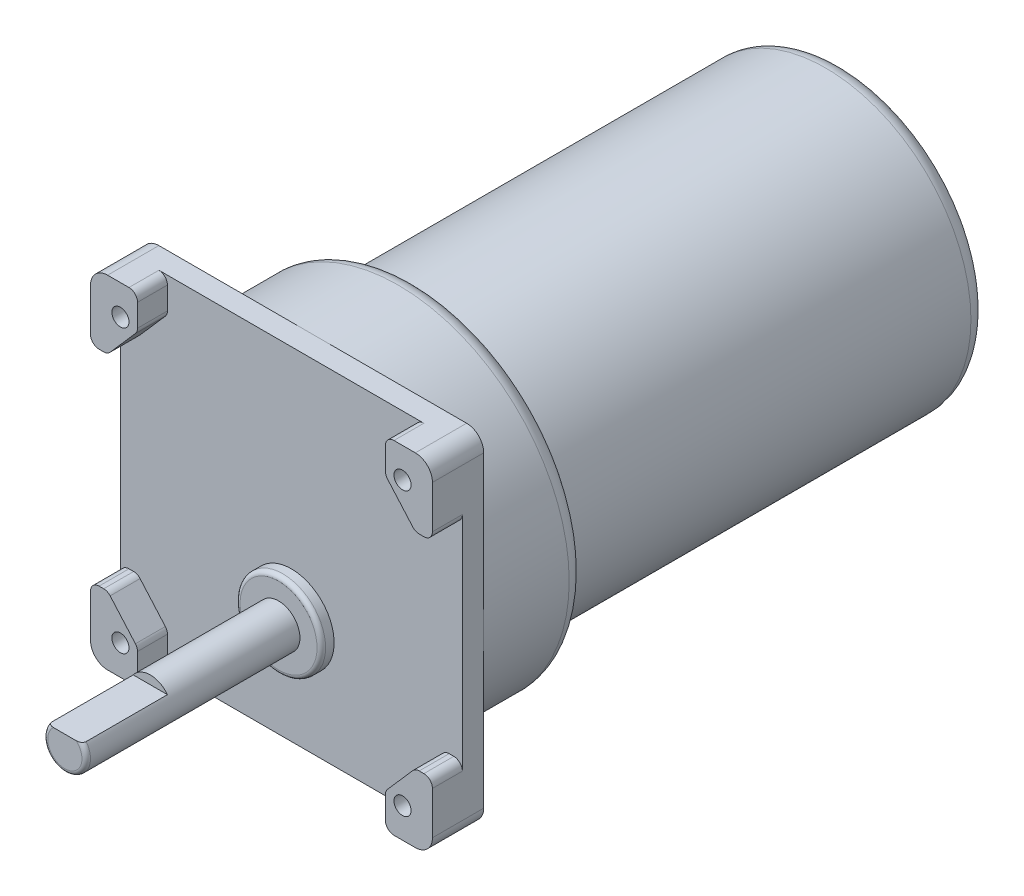
from build123d import *

# Parameters (mm, degrees)
SKETCH1_R               = 40
BOSS_EXTRUDE1_DEPTH     = 24
SKETCH2_W               = 80
SKETCH2_H               = 80
SKETCH2_R               = 2
BOSS_EXTRUDE2_DEPTH     = 5
FILLET1_R               = 4
SKETCH3_R               = 34
BOSS_EXTRUDE3_DEPTH     = 100
FILLET2_R               = 4
SKETCH4_R               = 10
BOSS_EXTRUDE4_DEPTH     = 3
SKETCH5_R               = 5
BOSS_EXTRUDE5_DEPTH     = 50
FILLET3_R               = 1
FILLET4_R               = 1
SKETCH6_W               = 26.979088542
SKETCH6_H               = 2
CUT_EXTRUDE1_DEPTH      = 1
CUT_EXTRUDE1_DEPTH_BACK = 81
SKETCH8_R               = 2
BOSS_EXTRUDE6_DEPTH     = 7
FILLET5_R               = 2


with BuildPart() as part:
    # Sketch1 → Boss-Extrude1 (new body)
    with BuildSketch(Plane.XY):
        Circle(SKETCH1_R)
    extrude(amount=BOSS_EXTRUDE1_DEPTH)

    # Sketch2 → Boss-Extrude2 (add)
    with BuildSketch(Plane.XY.offset(24)):
        Rectangle(SKETCH2_W, SKETCH2_H)
        with Locations((33, -33)):
            Circle(SKETCH2_R, mode=Mode.SUBTRACT)
        with Locations((-33, 33)):
            Circle(SKETCH2_R, mode=Mode.SUBTRACT)
        with Locations((33, 33)):
            Circle(SKETCH2_R, mode=Mode.SUBTRACT)
        with Locations((-33, -33)):
            Circle(SKETCH2_R, mode=Mode.SUBTRACT)
    extrude(amount=BOSS_EXTRUDE2_DEPTH)

    # Fillet1
    fillet1_edges = [part.edges().sort_by_distance(p)[0] for p in [
        (40, 40, 26.5),
        (-40, 40, 26.5),
        (-40, -40, 26.5),
        (40, -40, 26.5),
    ]]
    fillet(fillet1_edges, radius=FILLET1_R)

    # Sketch3 → Boss-Extrude3 (add)
    with BuildSketch(Plane(origin=(0, 0, 0), x_dir=(-1, 0, 0), z_dir=(0, 0, -1))):
        Circle(SKETCH3_R)
    extrude(amount=BOSS_EXTRUDE3_DEPTH)

    # Fillet2
    fillet2_edges = [part.edges().sort_by_distance(p)[0] for p in [
        (-40, 0, 0),
        (34, 0, -100),
    ]]
    fillet(fillet2_edges, radius=FILLET2_R)

    # Sketch4 → Boss-Extrude4 (add)
    with BuildSketch(Plane.XY.offset(29)):
        with Locations((0, -15)):
            Circle(SKETCH4_R)
    extrude(amount=BOSS_EXTRUDE4_DEPTH)

    # Sketch5 → Boss-Extrude5 (add)
    with BuildSketch(Plane.XY.offset(32)):
        with Locations((0, -15)):
            Circle(SKETCH5_R)
    extrude(amount=BOSS_EXTRUDE5_DEPTH)

    # Fillet3
    fillet3_edges = [part.edges().sort_by_distance(p)[0] for p in [
        (-10, -15, 32),
    ]]
    fillet(fillet3_edges, radius=FILLET3_R)

    # Fillet4
    fillet4_edges = [part.edges().sort_by_distance(p)[0] for p in [
        (-5, -15, 82),
    ]]
    fillet(fillet4_edges, radius=FILLET4_R)

    # Sketch6 → Cut-Extrude1 (cut, two sides)
    with BuildSketch(Plane.ZY.offset(40)) as cut_extrude1_sk:
        with Locations((75.489544271, -11)):
            Rectangle(SKETCH6_W, SKETCH6_H)
    extrude(amount=CUT_EXTRUDE1_DEPTH, mode=Mode.SUBTRACT)
    extrude(cut_extrude1_sk.sketch, amount=-CUT_EXTRUDE1_DEPTH_BACK, mode=Mode.SUBTRACT)

    # Sketch8 → Boss-Extrude6 (add)
    with BuildSketch(Plane.XY.offset(29)):
        with BuildLine():
            Line((-36, -24), (-40, -24))
            Line((-40, -24), (-40, -36))
            ThreePointArc((-40, -36), (-38.828427125, -38.828427125), (-36, -40))
            Line((-36, -40), (-29, -40))
            Line((-29, -40), (-29, -32))
            Line((-29, -32), (-36, -24))
        make_face()
        with Locations((-33, -33)):
            Circle(SKETCH8_R, mode=Mode.SUBTRACT)
        with BuildLine():
            Line((29, -32), (29, -40))
            Line((29, -40), (36, -40))
            ThreePointArc((36, -40), (38.828427125, -38.828427125), (40, -36))
            Line((40, -36), (40, -24))
            Line((40, -24), (36, -24))
            Line((36, -24), (29, -32))
        make_face()
        with Locations((33, -33)):
            Circle(SKETCH8_R, mode=Mode.SUBTRACT)
        with BuildLine():
            Line((-40, 36), (-40, 24))
            Line((-40, 24), (-36, 24))
            Line((-36, 24), (-29, 32))
            Line((-29, 32), (-29, 40))
            Line((-29, 40), (-36, 40))
            ThreePointArc((-36, 40), (-38.828427125, 38.828427125), (-40, 36))
        make_face()
        with Locations((-33, 33)):
            Circle(SKETCH8_R, mode=Mode.SUBTRACT)
        with BuildLine():
            Line((36, 40), (29, 40))
            Line((29, 40), (29, 32))
            Line((29, 32), (36, 24))
            Line((36, 24), (40, 24))
            Line((40, 24), (40, 36))
            ThreePointArc((40, 36), (38.828427125, 38.828427125), (36, 40))
        make_face()
        with Locations((33, 33)):
            Circle(SKETCH8_R, mode=Mode.SUBTRACT)
    extrude(amount=BOSS_EXTRUDE6_DEPTH)

    # Fillet5
    fillet5_edges = [part.edges().sort_by_distance(p)[0] for p in [
        (-36, -24, 32.5),
        (-40, -24, 32.5),
        (-29, -40, 32.5),
        (-29, -32, 32.5),
        (36, -24, 32.5),
        (29, -32, 32.5),
        (29, -40, 32.5),
        (40, -24, 32.5),
        (-36, 24, 32.5),
        (-29, 32, 32.5),
        (-29, 40, 32.5),
        (-40, 24, 32.5),
        (36, 24, 32.5),
        (40, 24, 32.5),
        (29, 40, 32.5),
        (29, 32, 32.5),
    ]]
    fillet(fillet5_edges, radius=FILLET5_R)


solid = part.part
